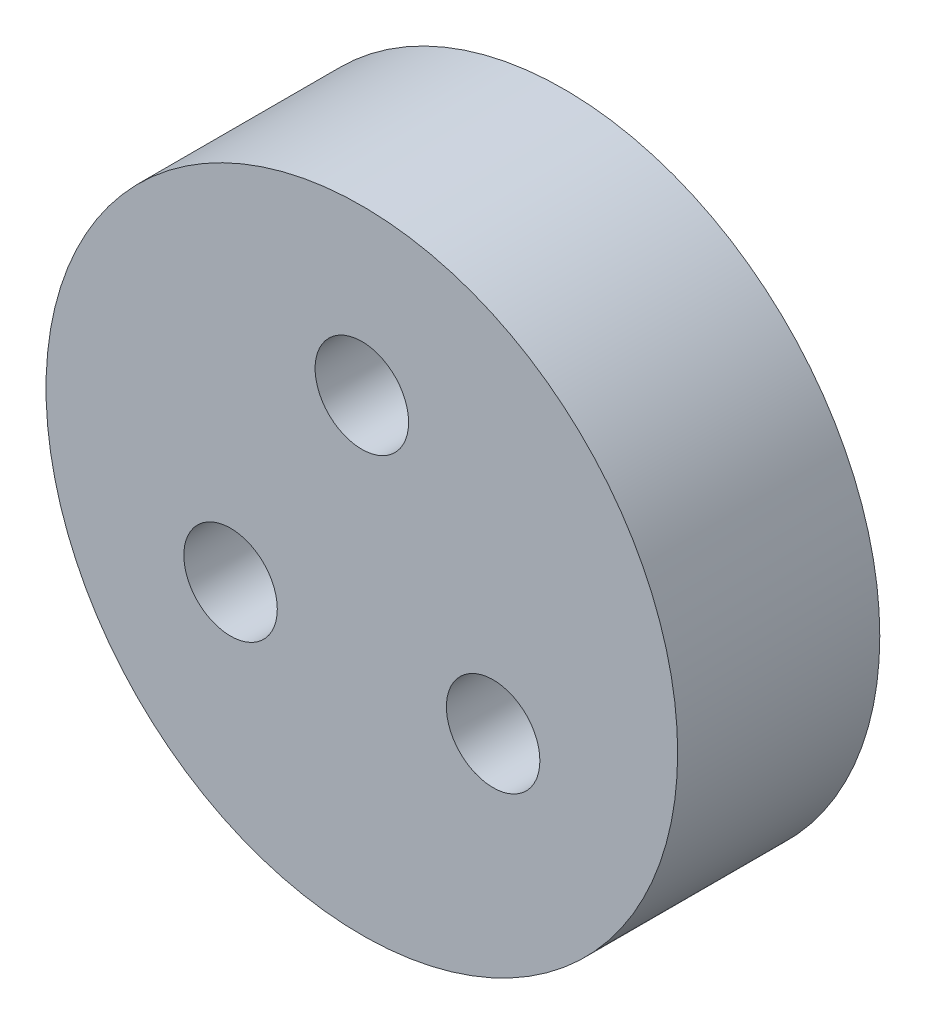
from build123d import *

# Parameters (mm, degrees)
SKETCH1_R           = 12.5
BOSS_EXTRUDE1_DEPTH = 8
SKETCH2_R           = 1.85
CUT_EXTRUDE1_DEPTH  = 8
CUT_EXTRUDE2_DEPTH  = 5
CIRPATTERN1_COUNT   = 3


with BuildPart() as part:
    # Sketch1 → Boss-Extrude1 (new body)
    with BuildSketch(Plane.XY):
        Circle(SKETCH1_R)
    extrude(amount=BOSS_EXTRUDE1_DEPTH)

    # Sketch2 → Cut-Extrude1 (cut)
    with BuildSketch(Plane.XY.offset(8)):
        with Locations((0, 6)):
            Circle(SKETCH2_R)
    cut_extrude1 = extrude(amount=-CUT_EXTRUDE1_DEPTH, mode=Mode.SUBTRACT)

    # Sketch3 → Cut-Extrude2 (cut)
    with BuildSketch(Plane(origin=(0, 0, 0), x_dir=(-1, 0, 0), z_dir=(0, 0, -1))):
        Polygon((3.233161507, 6), (1.616580754, 8.8), (-1.616580754, 8.8), (-3.233161507, 6), (-1.616580754, 3.2), (1.616580754, 3.2), align=None)
    cut_extrude2 = extrude(amount=-CUT_EXTRUDE2_DEPTH, mode=Mode.SUBTRACT)

    # CirPattern1: Cut-Extrude1, Cut-Extrude2 ×3 about axis
    cirpattern1_axis = Axis((0, 0, 0), (0, 0, 1))
    for i in range(1, CIRPATTERN1_COUNT):
        add(cut_extrude1.rotate(cirpattern1_axis, i * 360 / CIRPATTERN1_COUNT), mode=Mode.SUBTRACT)
        add(cut_extrude2.rotate(cirpattern1_axis, i * 360 / CIRPATTERN1_COUNT), mode=Mode.SUBTRACT)


solid = part.part
